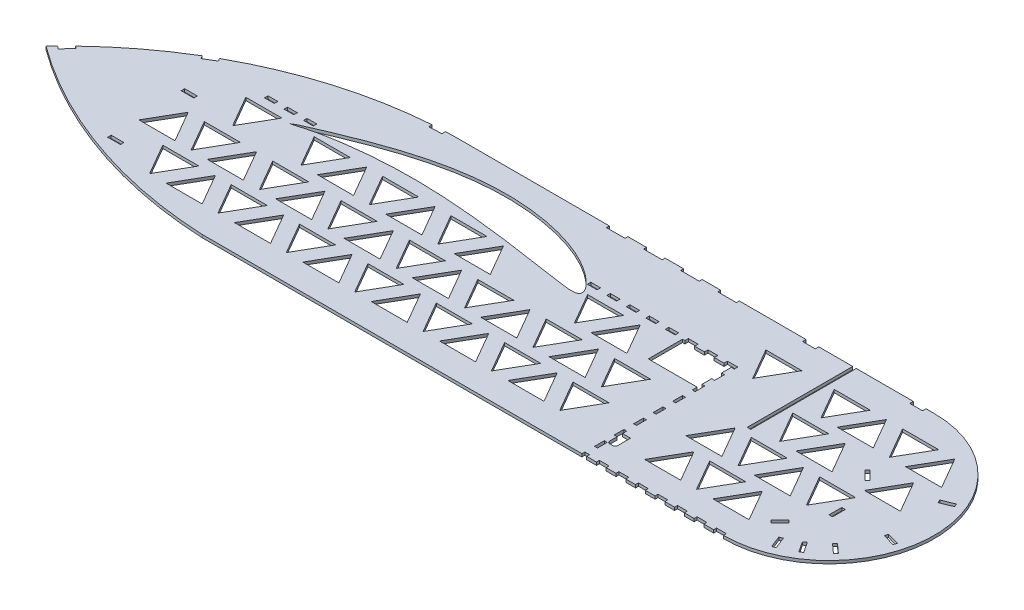
from build123d import *

# Parameters (mm, degrees)
BOSS_EXTRUDE1_DEPTH = 3
SKETCH2_W           = 3.6
SKETCH2_H           = 13
SKETCH2_W_2         = 13
SKETCH2_H_2         = 3.6
SKETCH2_W_3         = 19
SKETCH2_H_3         = 3
SKETCH2_W_4         = 10
SKETCH2_W_5         = 3
SKETCH2_H_4         = 10
SKETCH2_W_6         = 4.93
SKETCH2_H_5         = 108
CUT_EXTRUDE1_DEPTH  = 4


with BuildPart() as part:
    # Sketch1 → Boss-Extrude1 (new body)
    with BuildSketch(Plane(origin=(0, 0, 0), x_dir=(1, 0, 0), z_dir=(0, 1, 0))):
        with BuildLine():
            Line((266.408252791, 0), (800, 0))
            ThreePointArc((800, 0), (908, 108), (800, 216))
            Line((800, 216), (316.294556964, 216))
            ThreePointArc((316.294556964, 216), (154.432198565, 182.326352039), (19.429068043, 86.893169221))
            ThreePointArc((19.429068043, 86.893169221), (136.475600537, 25.133273094), (266.408252791, 0))
        make_face()
    extrude(amount=BOSS_EXTRUDE1_DEPTH)

    # Sketch2 → Cut-Extrude1 (cut, through all)
    with BuildSketch(Plane.XZ):
        Polygon((647.57, -153), (637.57, -153), (637.57, -156.6), (627.57, -156.6), (627.57, -153), (617.57, -153), (617.57, -156.6), (607.57, -156.6), (607.57, -153), (605.07, -153), (605.07, -118), (655.07, -118), (655.07, -113), (658.07, -113), (658.07, -123), (655.07, -123), (655.07, -133), (658.07, -133), (658.07, -143), (655.07, -143), (655.07, -153), (658.07, -153), (658.07, -156.6), (647.57, -156.6), align=None)
        Polygon((823.689305433, -121.232773417), (814.496917278, -130.425161573), (817.04250169, -132.970745985), (826.234889846, -123.77835783), align=None)
        Polygon((833.216286063, -28.127768374), (837.957262065, -16.0230938), (834.605198337, -14.710208137), (829.864222335, -26.814882712), align=None)
        with Locations((837.65655194, -78.816857664)):
            Rectangle(SKETCH2_W, SKETCH2_H)
        with BuildLine():
            Line((658.07, -25.473381029), (658.07, -33))
            Line((658.07, -33), (655.07, -33))
            Line((655.07, -33), (655.07, -43))
            Line((655.07, -43), (658.07, -43))
            Line((658.07, -43), (658.07, -38.673381029))
            Line((658.07, -38.673381029), (666.27, -38.673381029))
            Line((666.27, -38.673381029), (666.27, -25.473381029))
            ThreePointArc((666.27, -25.473381029), (665.537766953, -23.705614076), (663.77, -22.973381029))
            Line((663.77, -22.973381029), (660.57, -22.973381029))
            ThreePointArc((660.57, -22.973381029), (658.802233047, -23.705614076), (658.07, -25.473381029))
        make_face()
        with BuildLine():
            Line((212.57, -142.861782597), (212.57, -142.894782597))
            add(Edge.make_bspline(
                [(212.57, -142.894782597), (212.815137814, -143.060102486), (213.721483955, -143.671338431), (215.664179604, -144.820627165), (218.723437449, -146.377902142), (222.783765044, -148.180430449), (227.75908382, -150.380753256), (233.673151887, -152.972942719), (243.334631626, -157.073964415), (254.071597155, -161.528560196), (265.811315632, -166.151386352), (275.559769605, -169.792616013), (285.820264156, -173.389650289), (300.213165162, -178.042893994), (315.047470761, -182.21442891), (330.216772764, -185.678244178), (341.716798025, -187.862793988), (353.238408154, -189.570546018), (364.74982071, -190.789827969), (376.222154657, -191.489317525), (387.611451467, -191.686885836), (398.853751386, -191.364655348), (413.421420996, -190.296341642), (427.580802498, -188.300042396), (441.195366572, -185.427458978), (450.821943115, -182.919735681), (459.948918056, -180.069695278), (468.511745548, -176.887644359), (476.453624938, -173.424739179), (483.715148146, -169.728859345), (490.24814377, -165.884833696), (496.019667562, -162.00694583), (500.998027396, -158.185747413), (505.147593549, -154.484087589), (508.447339472, -150.982728864), (510.852240131, -147.780842115), (512.23052565, -145.118995071), (512.672376723, -143.038033672), (512.365957104, -141.293980261), (510.836297954, -139.867947677), (508.300825673, -139.204557497), (504.990749494, -138.996901122), (500.845143819, -139.232879923), (495.886387834, -139.807005807), (490.127383335, -140.633765729), (483.600688534, -141.61415409), (476.345974836, -142.681971784), (468.41886468, -143.870863791), (459.86962452, -145.152957933), (447.40415706, -147.014008038), (434.302787697, -148.89198326), (413.230560269, -151.680307043), (394.916461571, -153.770522792), (372.413070638, -155.785169178), (353.278576878, -157.097400442), (334.10390548, -157.72050793), (318.83753012, -157.719300437), (307.569298967, -157.463067348), (296.54483902, -156.942386113), (285.853643217, -156.19861473), (275.586288909, -155.254588864), (265.829573747, -154.156930461), (256.673464041, -152.912824912), (248.205041684, -151.55854436), (240.510067524, -150.123302558), (233.666056009, -148.664077742), (227.735558734, -147.229571507), (222.771530443, -145.80558608), (218.774640723, -144.512633605), (215.724793866, -143.595242016), (213.753356987, -143.096728121), (212.816237246, -142.910670921), (212.57, -142.861782597)],
                knots=[0, 0, 0, 0, 0.001413477, 0.005226038, 0.010781091, 0.017815608, 0.026460951, 0.036790889, 0.048685593, 0.076639155, 0.092362872, 0.109003461, 0.126386903, 0.144339126, 0.181312719, 0.200023431, 0.218712626, 0.237261299, 0.255692478, 0.274037197, 0.292192583, 0.310132767, 0.327788163, 0.362001934, 0.378421226, 0.394286639, 0.40954344, 0.424114253, 0.43793778, 0.450941833, 0.463044023, 0.474154417, 0.484164575, 0.493023962, 0.500713088, 0.507125739, 0.512129705, 0.514904185, 0.517171427, 0.520261618, 0.5242453, 0.529497961, 0.536092185, 0.54406114, 0.553363127, 0.563904543, 0.575614949, 0.588420092, 0.60222661, 0.616944448, 0.648675826, 0.665501113, 0.718564132, 0.736789145, 0.773513212, 0.810244924, 0.828488569, 0.846493195, 0.864125178, 0.88124851, 0.897725282, 0.913415058, 0.928184346, 0.941897285, 0.954411455, 0.965602702, 0.975349728, 0.983575522, 0.990284579, 0.99543259, 0.998799869, 1, 1, 1, 1], degree=3))
        make_face()
        with Locations((134.542485822, -118.459135811)):
            Rectangle(SKETCH2_W_2, SKETCH2_H_2)
        with Locations((138.193962825, -39.604200299)):
            Rectangle(SKETCH2_W_2, SKETCH2_H_2)
        Polygon((237.285906423, -101.160362438), (274.226762414, -101.160362438), (255.756334419, -69.168642712), align=None)
        Polygon((879.46612068, -142.176464253), (891.512779688, -147.062976991), (892.865967831, -143.726979112), (880.819308823, -138.840466374), align=None)
        Polygon((883.56409693, -85.640734603), (896.049682188, -82.019939003), (895.047000329, -78.562392317), (882.561415072, -82.183187916), align=None)
        Polygon((865.40073975, -51.381643569), (875.050147879, -42.670218728), (872.637753308, -39.998074939), (862.988345179, -48.709499779), align=None)
        Polygon((849.114653162, -36.791532178), (856.271451565, -25.938871831), (853.266099469, -23.956989196), (846.109301065, -34.809649543), align=None)
        Polygon((822.408918344, -44.734564455), (813.216530188, -35.542176299), (810.670945776, -38.087760711), (819.863333931, -47.280148867), align=None)
        with Locations((785, -214.2)):
            Rectangle(SKETCH2_W_2, SKETCH2_H_2)
        with Locations((675.107627624, -214.2)):
            Rectangle(SKETCH2_W_2, SKETCH2_H_2)
        with Locations((590.701810534, -214.5)):
            Rectangle(SKETCH2_W_3, SKETCH2_H_3)
        with Locations((552.701810534, -214.5)):
            Rectangle(SKETCH2_W_3, SKETCH2_H_3)
        with Locations((514.701810534, -214.5)):
            Rectangle(SKETCH2_W_3, SKETCH2_H_3)
        with Locations((476.701810534, -214.5)):
            Rectangle(SKETCH2_W_3, SKETCH2_H_3)
        Polygon((286.653605669, -215.067910052), (299.639993398, -215.662665262), (299.804694841, -212.066434814), (286.818307112, -211.471679604), align=None)
        Polygon((107.891846949, -158.40758228), (119.051202256, -165.076074548), (120.897861653, -161.98579154), (109.738506346, -155.317299272), align=None)
        Polygon((25.225136805, -93.110530953), (34.089712558, -102.619437132), (36.722948115, -100.164631538), (27.858372362, -90.65572536), align=None)
        with Locations((532.57, -154.8)):
            Rectangle(SKETCH2_W_4, SKETCH2_H_2)
        with Locations((552.57, -154.8)):
            Rectangle(SKETCH2_W_4, SKETCH2_H_2)
        with Locations((572.57, -154.8)):
            Rectangle(SKETCH2_W_4, SKETCH2_H_2)
        with Locations((592.57, -154.8)):
            Rectangle(SKETCH2_W_4, SKETCH2_H_2)
        with Locations((656.57, -98)):
            Rectangle(SKETCH2_W_5, SKETCH2_H_4)
        with Locations((656.57, -78)):
            Rectangle(SKETCH2_W_5, SKETCH2_H_4)
        with Locations((656.57, -58)):
            Rectangle(SKETCH2_W_5, SKETCH2_H_4)
        with Locations((656.57, -18)):
            Rectangle(SKETCH2_W_5, SKETCH2_H_4)
        with Locations((657.535, -1.5)):
            Rectangle(SKETCH2_W_6, SKETCH2_H_3)
        with Locations((675, -1.5)):
            Rectangle(SKETCH2_W_4, SKETCH2_H_3)
        with Locations((695, -1.5)):
            Rectangle(SKETCH2_W_4, SKETCH2_H_3)
        with Locations((715, -1.5)):
            Rectangle(SKETCH2_W_4, SKETCH2_H_3)
        with Locations((735, -1.5)):
            Rectangle(SKETCH2_W_4, SKETCH2_H_3)
        with Locations((755, -1.5)):
            Rectangle(SKETCH2_W_4, SKETCH2_H_3)
        with Locations((775, -1.5)):
            Rectangle(SKETCH2_W_4, SKETCH2_H_3)
        with Locations((795, -1.5)):
            Rectangle(SKETCH2_W_4, SKETCH2_H_3)
        Polygon((202.285906423, -69.168642712), (239.226762414, -69.168642712), (220.756334419, -101.160362438), align=None)
        with Locations((182.07, -154.8)):
            Rectangle(SKETCH2_W_4, SKETCH2_H_2)
        with Locations((202.07, -154.8)):
            Rectangle(SKETCH2_W_4, SKETCH2_H_2)
        with Locations((222.07, -154.8)):
            Rectangle(SKETCH2_W_4, SKETCH2_H_2)
        with Locations((512.57, -154.8)):
            Rectangle(SKETCH2_W_4, SKETCH2_H_2)
        Polygon((202.285906423, -26.990109245), (239.226762414, -26.990109245), (220.756334419, -58.981828971), align=None)
        Polygon((132.285906423, -69.168642712), (169.226762414, -69.168642712), (150.756334419, -101.160362438), align=None)
        Polygon((167.285906423, -101.160362438), (204.226762414, -101.160362438), (185.756334419, -69.168642712), align=None)
        Polygon((166.955188323, -58.981828971), (203.896044314, -58.981828971), (185.425616319, -26.990109245), align=None)
        Polygon((236.955188323, -58.981828971), (273.896044314, -58.981828971), (255.425616319, -26.990109245), align=None)
        with Locations((718.2, -162)):
            Rectangle(SKETCH2_W, SKETCH2_H_5)
        Polygon((307.285906423, -101.160362438), (344.226762414, -101.160362438), (325.756334419, -69.168642712), align=None)
        Polygon((272.285906423, -69.168642712), (309.226762414, -69.168642712), (290.756334419, -101.160362438), align=None)
        Polygon((272.285906423, -26.990109245), (309.226762414, -26.990109245), (290.756334419, -58.981828971), align=None)
        Polygon((306.955188323, -58.981828971), (343.896044314, -58.981828971), (325.425616319, -26.990109245), align=None)
        Polygon((377.285906423, -101.160362438), (414.226762414, -101.160362438), (395.756334419, -69.168642712), align=None)
        Polygon((342.285906423, -69.168642712), (379.226762414, -69.168642712), (360.756334419, -101.160362438), align=None)
        Polygon((342.285906423, -26.990109245), (379.226762414, -26.990109245), (360.756334419, -58.981828971), align=None)
        Polygon((376.955188323, -58.981828971), (413.896044314, -58.981828971), (395.425616319, -26.990109245), align=None)
        Polygon((447.285906423, -101.160362438), (484.226762414, -101.160362438), (465.756334419, -69.168642712), align=None)
        Polygon((412.285906423, -69.168642712), (449.226762414, -69.168642712), (430.756334419, -101.160362438), align=None)
        Polygon((412.285906423, -26.990109245), (449.226762414, -26.990109245), (430.756334419, -58.981828971), align=None)
        Polygon((446.955188323, -58.981828971), (483.896044314, -58.981828971), (465.425616319, -26.990109245), align=None)
        Polygon((517.285906423, -101.160362438), (554.226762414, -101.160362438), (535.756334419, -69.168642712), align=None)
        Polygon((482.285906423, -69.168642712), (519.226762414, -69.168642712), (500.756334419, -101.160362438), align=None)
        Polygon((482.285906423, -26.990109245), (519.226762414, -26.990109245), (500.756334419, -58.981828971), align=None)
        Polygon((516.955188323, -58.981828971), (553.896044314, -58.981828971), (535.425616319, -26.990109245), align=None)
        Polygon((587.285906423, -101.160362438), (624.226762414, -101.160362438), (605.756334419, -69.168642712), align=None)
        Polygon((552.285906423, -69.168642712), (589.226762414, -69.168642712), (570.756334419, -101.160362438), align=None)
        Polygon((552.285906423, -26.990109245), (589.226762414, -26.990109245), (570.756334419, -58.981828971), align=None)
        Polygon((586.955188323, -58.981828971), (623.896044314, -58.981828971), (605.425616319, -26.990109245), align=None)
        Polygon((727.285906423, -101.160362438), (764.226762414, -101.160362438), (745.756334419, -69.168642712), align=None)
        Polygon((692.285906423, -69.168642712), (729.226762414, -69.168642712), (710.756334419, -101.160362438), align=None)
        Polygon((692.285906423, -26.990109245), (729.226762414, -26.990109245), (710.756334419, -58.981828971), align=None)
        Polygon((726.955188323, -58.981828971), (763.896044314, -58.981828971), (745.425616319, -26.990109245), align=None)
        Polygon((797.285906423, -101.160362438), (834.226762414, -101.160362438), (815.756334419, -69.168642712), align=None)
        Polygon((762.285906423, -69.168642712), (799.226762414, -69.168642712), (780.756334419, -101.160362438), align=None)
        Polygon((762.285906423, -26.990109245), (799.226762414, -26.990109245), (780.756334419, -58.981828971), align=None)
        Polygon((236.955188323, -143.981828971), (273.896044314, -143.981828971), (255.425616319, -111.990109245), align=None)
        Polygon((272.285906423, -111.990109245), (309.226762414, -111.990109245), (290.756334419, -143.981828971), align=None)
        Polygon((306.955188323, -143.981828971), (343.896044314, -143.981828971), (325.425616319, -111.990109245), align=None)
        Polygon((342.285906423, -111.990109245), (379.226762414, -111.990109245), (360.756334419, -143.981828971), align=None)
        Polygon((376.955188323, -143.981828971), (413.896044314, -143.981828971), (395.425616319, -111.990109245), align=None)
        Polygon((412.285906423, -111.990109245), (449.226762414, -111.990109245), (430.756334419, -143.981828971), align=None)
        Polygon((516.955188323, -143.981828971), (553.896044314, -143.981828971), (535.425616319, -111.990109245), align=None)
        Polygon((552.285906423, -111.990109245), (589.226762414, -111.990109245), (570.756334419, -143.981828971), align=None)
        Polygon((657.285906423, -186.160362438), (694.226762414, -186.160362438), (675.756334419, -154.168642712), align=None)
        Polygon((727.285906423, -186.160362438), (764.226762414, -186.160362438), (745.756334419, -154.168642712), align=None)
        Polygon((726.955188323, -143.981828971), (763.896044314, -143.981828971), (745.425616319, -111.990109245), align=None)
        Polygon((797.285906423, -186.160362438), (834.226762414, -186.160362438), (815.756334419, -154.168642712), align=None)
        Polygon((762.285906423, -154.168642712), (799.226762414, -154.168642712), (780.756334419, -186.160362438), align=None)
        Polygon((762.285906423, -111.990109245), (799.226762414, -111.990109245), (780.756334419, -143.981828971), align=None)
        Polygon((832.285906423, -154.168642712), (869.226762414, -154.168642712), (850.756334419, -186.160362438), align=None)
        Polygon((832.285906423, -111.990109245), (869.226762414, -111.990109245), (850.756334419, -143.981828971), align=None)
        Polygon((166.955188323, -143.981828971), (203.896044314, -143.981828971), (185.425616319, -111.990109245), align=None)
    extrude(amount=-CUT_EXTRUDE1_DEPTH, mode=Mode.SUBTRACT)


solid = part.part
